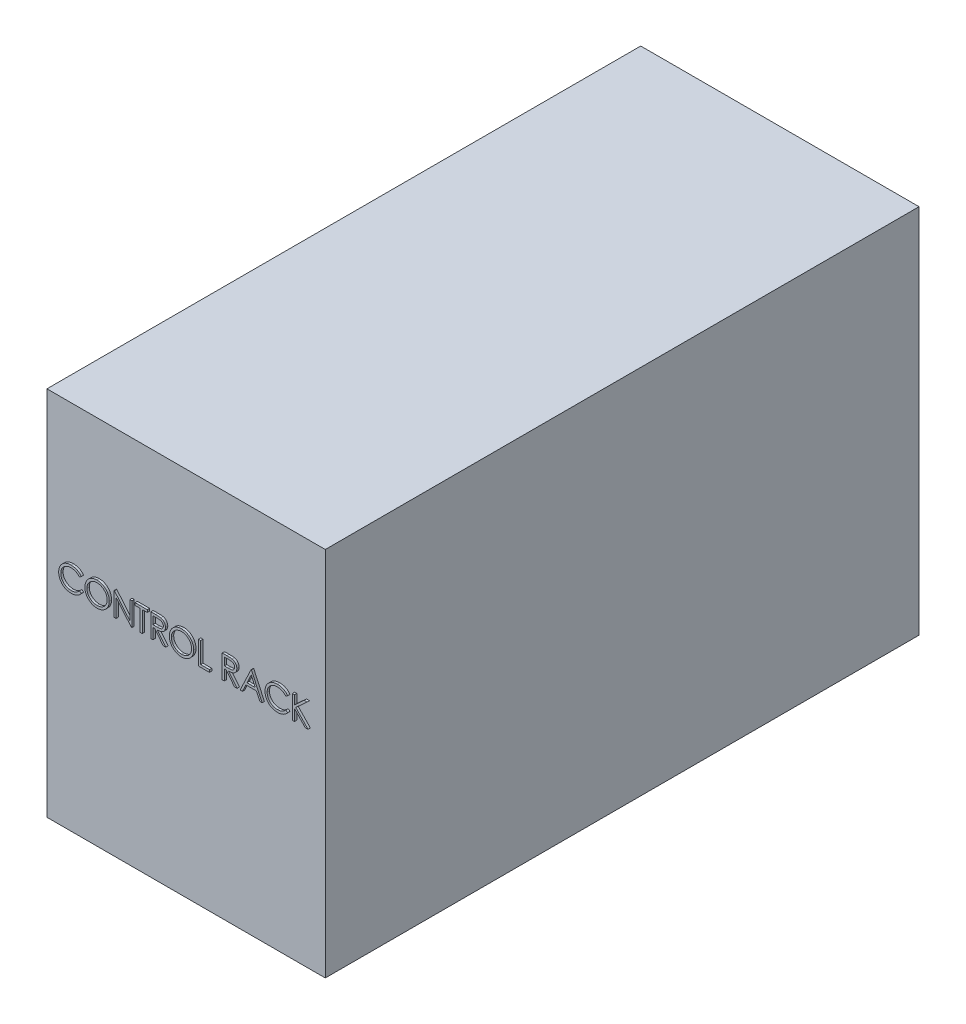
from build123d import *

# Parameters (mm, degrees)
SKETCH1_W           = 600
SKETCH1_H           = 800
BOSS_EXTRUDE1_DEPTH = 1280
BOSS_EXTRUDE2_DEPTH = 5


with BuildPart() as part:
    # Sketch1 → Boss-Extrude1 (new body)
    with BuildSketch(Plane.XY):
        with Locations((-300, 400)):
            Rectangle(SKETCH1_W, SKETCH1_H)
    extrude(amount=BOSS_EXTRUDE1_DEPTH)

    # Sketch2 → Boss-Extrude2 (add)
    with BuildSketch(Plane.XY.offset(1280)):
        with BuildLine():
            Line((-520.987509976, 491.534086131), (-524.913792027, 488.529278439))
            add(Edge.make_bspline(
                [(-524.913792027, 488.529278439), (-525.193876147, 488.863078008), (-525.750268244, 489.526176804), (-526.645399709, 490.457313153), (-527.578280321, 491.329674031), (-528.548553482, 492.147415168), (-529.57368376, 492.881940393), (-530.628838027, 493.571527578), (-531.731667244, 494.18963812), (-533.256692025, 494.93910935), (-535.251661286, 495.721197279), (-537.76301613, 496.376957726), (-540.384603251, 496.794403093), (-542.173140388, 496.839615114), (-543.08286254, 496.862611772)],
                knots=[0, 0, 0, 0, 0.001306928, 0.002596236, 0.003871776, 0.005137526, 0.006399704, 0.007652669, 0.008917388, 0.010189541, 0.012748886, 0.015328999, 0.017963804, 0.020691273, 0.020691273, 0.020691273, 0.020691273], degree=3))
            add(Edge.make_bspline(
                [(-543.08286254, 496.862611772), (-543.584052531, 496.856840879), (-544.581780996, 496.845352652), (-546.062473474, 496.693793721), (-547.515517062, 496.480776434), (-548.939966579, 496.164700388), (-550.334008844, 495.765091544), (-551.706757445, 495.287585631), (-553.038337442, 494.696802205), (-554.347169417, 494.043827062), (-555.601158145, 493.306292138), (-556.787658828, 492.501815682), (-557.902344084, 491.639400019), (-558.946095686, 490.715812785), (-559.919980662, 489.735213349), (-560.816942245, 488.687151327), (-561.633876677, 487.574977419), (-562.386977035, 486.413357311), (-563.061444655, 485.205674574), (-563.626157217, 483.947459282), (-564.126230392, 482.66025781), (-564.521933858, 481.329526941), (-564.835141241, 479.964630286), (-565.051250717, 478.561904744), (-565.20108602, 477.124280749), (-565.212517118, 476.149861998), (-565.218279207, 475.65868549)],
                knots=[0, 0, 0, 0, 0.001502938, 0.002991927, 0.004460872, 0.005906862, 0.007365217, 0.008809749, 0.010263039, 0.011732257, 0.013195831, 0.014623739, 0.016030161, 0.017420911, 0.018801997, 0.020173022, 0.02155527, 0.022938824, 0.024324153, 0.025700181, 0.027072961, 0.028464036, 0.029861154, 0.031270712, 0.03271982, 0.034192721, 0.034192721, 0.034192721, 0.034192721], degree=3))
            add(Edge.make_bspline(
                [(-565.218279207, 475.65868549), (-565.200253221, 474.919666634), (-565.164861588, 473.468701136), (-564.849885387, 471.3434067), (-564.371241226, 469.307397074), (-563.653875841, 467.373399327), (-562.769317976, 465.51756564), (-561.651594954, 463.771296306), (-560.357072992, 462.108202527), (-558.867438428, 460.567588988), (-557.233069628, 459.160250055), (-555.479528034, 457.920956034), (-553.611181066, 456.887886284), (-551.648657777, 456.028229905), (-549.57685615, 455.36741951), (-547.39950183, 454.902217746), (-545.121330469, 454.598758024), (-543.564624756, 454.569705337), (-542.772365745, 454.554919464)],
                knots=[0, 0, 0, 0, 0.002215807, 0.004350442, 0.006432355, 0.008479254, 0.010526472, 0.012588314, 0.014686091, 0.01683956, 0.019005825, 0.021148272, 0.023269069, 0.025399683, 0.027566295, 0.029780381, 0.032072497, 0.034448006, 0.034448006, 0.034448006, 0.034448006], degree=3))
            add(Edge.make_bspline(
                [(-542.772365745, 454.554919464), (-541.899470188, 454.579044889), (-540.181402918, 454.626529497), (-537.661859684, 455.028804484), (-535.249920175, 455.681060454), (-532.945454653, 456.593887915), (-530.754959708, 457.780534885), (-528.675007417, 459.219075991), (-526.703842125, 460.923195031), (-525.518538093, 462.224382577), (-524.913792027, 462.888252798)],
                knots=[0, 0, 0, 0, 0.002617423, 0.005151715, 0.007632497, 0.01010063, 0.0125699, 0.015089841, 0.017674403, 0.020366646, 0.020366646, 0.020366646, 0.020366646], degree=3))
            Line((-524.913792027, 462.888252798), (-520.987509976, 459.913493182))
            add(Edge.make_bspline(
                [(-520.987509976, 459.913493182), (-521.303482974, 459.505801012), (-521.933915478, 458.692369494), (-522.954744292, 457.545630783), (-524.030134255, 456.467001705), (-525.168072969, 455.465178544), (-526.355469992, 454.52011475), (-527.613645883, 453.658660018), (-528.926060633, 452.868790242), (-530.288267474, 452.145548463), (-531.698819086, 451.503873506), (-533.156025299, 450.954533966), (-534.653604949, 450.481321258), (-536.191626498, 450.092007877), (-537.773280167, 449.78813525), (-539.392858368, 449.584997038), (-541.053856586, 449.445826832), (-542.174448316, 449.43314232), (-542.742317668, 449.426714336)],
                knots=[0, 0, 0, 0, 0.001547046, 0.003086683, 0.004602316, 0.006113674, 0.007632581, 0.00915228, 0.010684502, 0.012225799, 0.013776731, 0.015330023, 0.016894897, 0.018486058, 0.020087025, 0.021723198, 0.023380963, 0.025084159, 0.025084159, 0.025084159, 0.025084159], degree=3))
            add(Edge.make_bspline(
                [(-542.742317668, 449.426714336), (-543.28008434, 449.430457087), (-544.343451342, 449.437857913), (-545.913433508, 449.557746019), (-547.441856091, 449.721313689), (-548.924350746, 449.967601276), (-550.369007532, 450.258234705), (-551.762730168, 450.647824085), (-553.119233173, 451.084240751), (-554.433066611, 451.597169133), (-555.705348037, 452.175971741), (-556.931973914, 452.830136868), (-558.112380091, 453.554163506), (-559.258171817, 454.332092226), (-560.352423013, 455.188910825), (-561.404616232, 456.112719889), (-562.420651607, 457.100405757), (-563.049261392, 457.812617947), (-563.365314463, 458.170704721)],
                knots=[0, 0, 0, 0, 0.00161286, 0.003189231, 0.004721159, 0.006222895, 0.00769617, 0.009139486, 0.010561656, 0.011969683, 0.013368094, 0.014752662, 0.016137194, 0.017520712, 0.018905171, 0.020303439, 0.021719989, 0.023152386, 0.023152386, 0.023152386, 0.023152386], degree=3))
            add(Edge.make_bspline(
                [(-563.365314463, 458.170704721), (-563.871537942, 458.792721705), (-564.877873325, 460.02924614), (-566.16538309, 462.033331586), (-567.267491021, 464.12573457), (-568.158575604, 466.317447838), (-568.855186078, 468.60355337), (-569.337774579, 470.985203576), (-569.651368928, 473.460174179), (-569.687230197, 475.143556874), (-569.705458694, 475.999230362)],
                knots=[0, 0, 0, 0, 0.002404368, 0.004779708, 0.007131768, 0.009490218, 0.011866572, 0.014290574, 0.016772771, 0.019338829, 0.019338829, 0.019338829, 0.019338829], degree=3))
            add(Edge.make_bspline(
                [(-569.705458694, 475.999230362), (-569.683241643, 476.898593984), (-569.639530983, 478.668035763), (-569.268162476, 481.264806524), (-568.670751102, 483.752683651), (-567.822224122, 486.127022859), (-566.746433389, 488.400312577), (-565.417481762, 490.555186932), (-563.850808302, 492.605426927), (-562.058700192, 494.519923374), (-560.093452545, 496.270485554), (-557.988898061, 497.810574179), (-555.749155962, 499.092252979), (-553.398900938, 500.163626728), (-550.920534058, 500.987119059), (-548.319343071, 501.563593154), (-545.600215717, 501.922409101), (-543.745038207, 501.967769214), (-542.802413822, 501.9908169)],
                knots=[0, 0, 0, 0, 0.00269699, 0.00530616, 0.007852064, 0.010361113, 0.012856571, 0.01538349, 0.017941678, 0.020585017, 0.023238413, 0.025826834, 0.028393517, 0.030966525, 0.033563748, 0.036212376, 0.038949263, 0.041776339, 0.041776339, 0.041776339, 0.041776339], degree=3))
            add(Edge.make_bspline(
                [(-542.802413822, 501.9908169), (-542.227921366, 501.983929212), (-541.090771404, 501.970295726), (-539.408590656, 501.837350839), (-537.770843128, 501.615727893), (-536.176400527, 501.314069752), (-534.61750601, 500.939679446), (-533.106073998, 500.451960898), (-531.633235614, 499.894296165), (-530.208279783, 499.252032366), (-528.838043352, 498.531078918), (-527.522953088, 497.739427153), (-526.273455106, 496.878058503), (-525.080757271, 495.954298854), (-523.964811399, 494.94860515), (-522.893933134, 493.888639493), (-521.90448916, 492.743870576), (-521.293729232, 491.938085806), (-520.987509976, 491.534086131)],
                knots=[0, 0, 0, 0, 0.001723222, 0.003410945, 0.00505836, 0.006679008, 0.008277466, 0.009864461, 0.011440036, 0.013000095, 0.014550251, 0.016082473, 0.017602172, 0.019100832, 0.020604704, 0.022106173, 0.02361846, 0.025139083, 0.025139083, 0.025139083, 0.025139083], degree=3))
        make_face()
        with BuildLine():
            add(Edge.make_bspline(
                [(-487.333663822, 501.9908169), (-486.407833738, 501.967367195), (-484.589427067, 501.921310039), (-481.916928528, 501.568751417), (-479.365570024, 500.958817274), (-476.914568041, 500.146488953), (-474.593239804, 499.062854876), (-472.384112769, 497.753067043), (-470.292443143, 496.203403346), (-468.346423406, 494.425842963), (-466.565609831, 492.491793621), (-464.996668599, 490.427823477), (-463.681778688, 488.246412016), (-462.601981729, 485.954114435), (-461.754858733, 483.556114893), (-461.170300966, 481.039629139), (-460.796898821, 478.420962138), (-460.753244858, 476.634864071), (-460.731099719, 475.728797669)],
                knots=[0, 0, 0, 0, 0.002777041, 0.005454338, 0.008068425, 0.01063716, 0.01318702, 0.015737884, 0.018330081, 0.020981964, 0.023633205, 0.026207343, 0.028746163, 0.031259727, 0.033797105, 0.036360151, 0.038999083, 0.041716086, 0.041716086, 0.041716086, 0.041716086], degree=3))
            add(Edge.make_bspline(
                [(-460.731099719, 475.728797669), (-460.753241613, 474.829405579), (-460.796885849, 473.056599572), (-461.170725528, 470.45455037), (-461.757025528, 467.953254706), (-462.594115045, 465.556888238), (-463.668764737, 463.262923041), (-464.992410039, 461.077395128), (-466.551570193, 458.999588009), (-468.325953779, 457.05226422), (-470.260254379, 455.266586067), (-472.334972476, 453.710602129), (-474.503448475, 452.371686063), (-476.793587163, 451.303347863), (-479.175016261, 450.449463286), (-481.669049448, 449.867282857), (-484.26400022, 449.491753667), (-486.033585988, 449.448632011), (-486.933022796, 449.426714336)],
                knots=[0, 0, 0, 0, 0.00269699, 0.005316081, 0.007869381, 0.010393996, 0.012916623, 0.015455444, 0.018045589, 0.020697472, 0.023348712, 0.025930847, 0.028466307, 0.03097987, 0.033498358, 0.036041916, 0.038651085, 0.041348076, 0.041348076, 0.041348076, 0.041348076], degree=3))
            add(Edge.make_bspline(
                [(-486.933022796, 449.426714336), (-487.839084496, 449.448848434), (-489.625173295, 449.492480633), (-492.247130944, 449.866500702), (-494.765384427, 450.45137647), (-497.172732302, 451.287225559), (-499.47051701, 452.367471712), (-501.663232477, 453.684677127), (-503.742077438, 455.247636287), (-505.689816673, 457.021444495), (-507.471948076, 458.952466667), (-509.025653443, 461.021527454), (-510.343155062, 463.188033977), (-511.419774097, 465.457998608), (-512.272123517, 467.820447789), (-512.853620919, 470.291140325), (-513.229848805, 472.855990408), (-513.273203755, 474.602317527), (-513.295202284, 475.488413054)],
                knots=[0, 0, 0, 0, 0.002717003, 0.005355936, 0.007928729, 0.010462803, 0.01298543, 0.015532831, 0.018122976, 0.020774859, 0.023426099, 0.025994209, 0.02852446, 0.031019918, 0.033519534, 0.036043612, 0.038623026, 0.041279992, 0.041279992, 0.041279992, 0.041279992], degree=3))
            add(Edge.make_bspline(
                [(-513.295202284, 475.488413054), (-513.287564634, 476.08316547), (-513.272385686, 477.265167235), (-513.089647222, 479.02040438), (-512.824480062, 480.747413776), (-512.44445274, 482.441284462), (-511.947428926, 484.097869957), (-511.360971391, 485.728595141), (-510.644687886, 487.316934051), (-509.834964343, 488.870411076), (-508.931224228, 490.364809731), (-507.932999236, 491.777375204), (-506.875351115, 493.119960872), (-505.715874063, 494.357775213), (-504.492781989, 495.526827447), (-503.18623373, 496.609151976), (-501.804201668, 497.614508418), (-500.3407391, 498.520513291), (-498.831906601, 499.3399295), (-497.276524062, 500.043098799), (-495.695715897, 500.646613964), (-494.08207807, 501.13576861), (-492.439895611, 501.521940552), (-490.765584403, 501.784902748), (-489.060478314, 501.968107289), (-487.911745186, 501.983214461), (-487.333663822, 501.9908169)],
                knots=[0, 0, 0, 0, 0.001783556, 0.003544611, 0.005288464, 0.007023435, 0.008747414, 0.010474271, 0.012218383, 0.013970071, 0.015727334, 0.017452942, 0.019156402, 0.020850296, 0.022536442, 0.02422924, 0.025936201, 0.027659336, 0.029389182, 0.031083519, 0.032776316, 0.034461928, 0.036138318, 0.037832715, 0.039543932, 0.041277428, 0.041277428, 0.041277428, 0.041277428], degree=3))
        make_face()
        with BuildLine():
            add(Edge.make_bspline(
                [(-487.113311258, 496.862611772), (-487.587806023, 496.856827625), (-488.532259351, 496.845314629), (-489.936324154, 496.69366155), (-491.321923209, 496.477520279), (-492.689342668, 496.169212839), (-494.032861088, 495.749154942), (-495.365001676, 495.265713397), (-496.673616731, 494.676840674), (-497.954386129, 494.011516326), (-499.19603006, 493.275103172), (-500.367640081, 492.461220785), (-501.47224928, 491.588955725), (-502.50715309, 490.656272334), (-503.469312692, 489.65842088), (-504.37766557, 488.610528935), (-505.195802451, 487.482644777), (-505.945596405, 486.305353251), (-506.616565552, 485.080187805), (-507.213213477, 483.820046915), (-507.701270745, 482.51465139), (-508.099304692, 481.178163424), (-508.42930199, 479.812699715), (-508.638358049, 478.407901874), (-508.791677469, 476.970828845), (-508.802532404, 475.999659502), (-508.808022796, 475.508445105)],
                knots=[0, 0, 0, 0, 0.00142284, 0.002832077, 0.004231743, 0.005628862, 0.007032428, 0.008452092, 0.00987789, 0.011333835, 0.012780172, 0.014205477, 0.015610187, 0.017000143, 0.018381374, 0.019766522, 0.021156839, 0.022557257, 0.023951357, 0.025344881, 0.026736387, 0.028127462, 0.02952684, 0.030946292, 0.032385431, 0.033858332, 0.033858332, 0.033858332, 0.033858332], degree=3))
            add(Edge.make_bspline(
                [(-508.808022796, 475.508445105), (-508.789810483, 474.786127665), (-508.753981228, 473.365105804), (-508.440301654, 471.282703749), (-507.957130591, 469.281442515), (-507.244882499, 467.372272383), (-506.354159432, 465.538782628), (-505.253775286, 463.797238275), (-503.950074063, 462.147168641), (-502.46916654, 460.60009337), (-500.850270732, 459.188010453), (-499.131231733, 457.948533186), (-497.330465911, 456.899815332), (-495.443277301, 456.045457155), (-493.479741029, 455.368460901), (-491.427204586, 454.904480456), (-489.299340878, 454.599116808), (-487.848902947, 454.569791723), (-487.113311258, 454.554919464)],
                knots=[0, 0, 0, 0, 0.002165779, 0.004260757, 0.006303756, 0.008331847, 0.01036105, 0.012409076, 0.014498972, 0.016659673, 0.018824919, 0.020934713, 0.023008224, 0.025065634, 0.027140306, 0.029227344, 0.031370516, 0.033575884, 0.033575884, 0.033575884, 0.033575884], degree=3))
            add(Edge.make_bspline(
                [(-487.113311258, 454.554919464), (-486.618889806, 454.561712384), (-485.638303572, 454.575184783), (-484.17979611, 454.710880167), (-482.747564514, 454.928478301), (-481.343617659, 455.241773381), (-479.969548925, 455.63387633), (-478.619623166, 456.099701016), (-477.308219018, 456.680861068), (-476.018792764, 457.322974662), (-474.78456074, 458.054976913), (-473.60633885, 458.841236193), (-472.513824852, 459.712216489), (-471.47969526, 460.631042383), (-470.513585418, 461.616240209), (-469.6220285, 462.666529093), (-468.808026612, 463.788538482), (-468.058517375, 464.964044278), (-467.389899336, 466.192562174), (-466.807340778, 467.457271859), (-466.313110552, 468.755059135), (-465.914131911, 470.087795871), (-465.601482459, 471.452950853), (-465.386055031, 472.85235197), (-465.235363051, 474.28319972), (-465.224004805, 475.250969091), (-465.218279207, 475.738813695)],
                knots=[0, 0, 0, 0, 0.001482913, 0.002941062, 0.004390205, 0.005826413, 0.007253126, 0.008675437, 0.010106362, 0.011553184, 0.012994413, 0.014408412, 0.015799053, 0.017182317, 0.018556375, 0.019935026, 0.021311346, 0.022711764, 0.024114651, 0.025503957, 0.026886096, 0.028277171, 0.029674289, 0.031083847, 0.032522987, 0.033985875, 0.033985875, 0.033985875, 0.033985875], degree=3))
            add(Edge.make_bspline(
                [(-465.218279207, 475.738813695), (-465.224009392, 476.223320899), (-465.23537627, 477.184430187), (-465.385983051, 478.605299021), (-465.601710056, 479.994630613), (-465.912605885, 481.346970656), (-466.313322367, 482.662663871), (-466.807427087, 483.940474553), (-467.390074222, 485.185163054), (-468.058763142, 486.393653011), (-468.810417763, 487.553292125), (-469.631764096, 488.661898018), (-470.536983355, 489.698651466), (-471.500212282, 490.689147095), (-472.545510644, 491.612259804), (-473.668143416, 492.468295813), (-474.85448167, 493.277914017), (-476.110585033, 494.008279186), (-477.40692723, 494.682768225), (-478.737126629, 495.260639699), (-480.086113767, 495.751669975), (-481.450458229, 496.170483762), (-482.841643633, 496.476312764), (-484.25026976, 496.693856333), (-485.674387739, 496.845261846), (-486.632148021, 496.856810111), (-487.113311258, 496.862611772)],
                knots=[0, 0, 0, 0, 0.001452876, 0.002882048, 0.004281713, 0.005669068, 0.007040971, 0.008404402, 0.009775537, 0.011160866, 0.01254442, 0.013918625, 0.015296183, 0.016670242, 0.018060991, 0.019475345, 0.020903252, 0.022366826, 0.023831668, 0.025284958, 0.026714024, 0.028136758, 0.02956319, 0.030982641, 0.032411812, 0.033854676, 0.033854676, 0.033854676, 0.033854676], degree=3))
        make_face(mode=Mode.SUBTRACT)
        Polygon((-450.474689463, 450.708765618), (-450.474689463, 500.708765618), (-449.533183053, 500.708765618), (-416.500330489, 461.355800875), (-416.500330489, 500.708765618), (-412.013151002, 500.708765618), (-412.013151002, 450.708765618), (-413.034785617, 450.708765618), (-445.987509976, 489.971586131), (-445.987509976, 450.708765618), align=None)
        Polygon((-404.96186895, 495.58056049), (-404.96186895, 500.708765618), (-378.679817668, 500.708765618), (-378.679817668, 495.58056049), (-389.577253566, 495.58056049), (-389.577253566, 450.708765618), (-394.064433053, 450.708765618), (-394.064433053, 495.58056049), align=None)
        with BuildLine():
            Line((-370.987509976, 500.708765618), (-360.98150036, 500.708765618))
            add(Edge.make_bspline(
                [(-360.98150036, 500.708765618), (-360.313769953, 500.706542961), (-359.031653604, 500.702275214), (-357.194892599, 500.678478601), (-355.525934071, 500.610273519), (-354.025650652, 500.551579469), (-352.694069867, 500.444551736), (-351.52710857, 500.342256777), (-350.530141463, 500.208347338), (-349.926629302, 500.083984152), (-349.65337536, 500.027675875)],
                knots=[0, 0, 0, 0, 0.00200323, 0.003846424, 0.00551017, 0.007014209, 0.0083501, 0.009517171, 0.010528542, 0.011365345, 0.011365345, 0.011365345, 0.011365345], degree=3))
            add(Edge.make_bspline(
                [(-349.65337536, 500.027675875), (-349.287566444, 499.937293512), (-348.563752309, 499.758456889), (-347.521608508, 499.380462591), (-346.528546738, 498.943039382), (-345.588692104, 498.429271949), (-344.70675223, 497.835346525), (-343.873633505, 497.171516205), (-343.085555456, 496.441413265), (-342.374389311, 495.626629815), (-341.70383143, 494.771822534), (-341.138279622, 493.84748315), (-340.650758484, 492.8808899), (-340.262608241, 491.862212504), (-339.950065763, 490.801330048), (-339.729690914, 489.688632952), (-339.597531091, 488.529190451), (-339.584076012, 487.738363183), (-339.577253566, 487.337371387)],
                knots=[0, 0, 0, 0, 0.001129726, 0.002235352, 0.003320462, 0.004382822, 0.005444001, 0.006506125, 0.007576154, 0.008661634, 0.009747438, 0.010831438, 0.011906471, 0.012990888, 0.014097058, 0.01522064, 0.016389772, 0.017592363, 0.017592363, 0.017592363, 0.017592363], degree=3))
            add(Edge.make_bspline(
                [(-339.577253566, 487.337371387), (-339.598239253, 486.671155607), (-339.639187764, 485.371196066), (-340.02097496, 483.484612046), (-340.646353813, 481.724764694), (-341.508115084, 480.093869866), (-342.605536166, 478.62371779), (-343.924461753, 477.332425571), (-345.465627632, 476.251855391), (-346.900332145, 475.50252961), (-348.167677855, 475.022630915), (-349.211010895, 474.684968646), (-350.349110573, 474.424083428), (-351.571072496, 474.190367259), (-352.88198186, 474.013914482), (-354.278696709, 473.884677418), (-355.762213161, 473.803905294), (-356.781342723, 473.791876653), (-357.30561895, 473.785688695)],
                knots=[0, 0, 0, 0, 0.00199681, 0.003896293, 0.005746413, 0.007583473, 0.009408398, 0.011228698, 0.013096305, 0.015036029, 0.016066512, 0.017159361, 0.018323032, 0.019566512, 0.02089094, 0.022289243, 0.023773779, 0.025346582, 0.025346582, 0.025346582, 0.025346582], degree=3))
            Line((-357.30561895, 473.785688695), (-338.936227925, 450.708765618))
            Line((-338.936227925, 450.708765618), (-344.48510613, 450.708765618))
            Line((-344.48510613, 450.708765618), (-362.854497155, 473.785688695))
            Line((-362.854497155, 473.785688695), (-366.500330489, 473.785688695))
            Line((-366.500330489, 473.785688695), (-366.500330489, 450.708765618))
            Line((-366.500330489, 450.708765618), (-370.987509976, 450.708765618))
            Line((-370.987509976, 450.708765618), (-370.987509976, 500.708765618))
        make_face()
        with BuildLine():
            Line((-366.500330489, 495.58056049), (-366.500330489, 478.913893823))
            Line((-366.500330489, 478.913893823), (-357.345683053, 478.843781644))
            add(Edge.make_bspline(
                [(-357.345683053, 478.843781644), (-356.918253925, 478.843592549), (-356.089774538, 478.843226029), (-354.891193612, 478.900279975), (-353.775192016, 478.965184521), (-352.746038414, 479.064460886), (-351.803273052, 479.192404768), (-350.947367149, 479.3524474), (-350.176923551, 479.538905438), (-349.278373002, 479.827500092), (-348.274993982, 480.284728924), (-347.184544556, 480.949950334), (-346.255939731, 481.786652037), (-345.47139884, 482.743415694), (-344.840978391, 483.795362106), (-344.396520472, 484.929881667), (-344.114485582, 486.118333067), (-344.081220647, 486.935163179), (-344.064433053, 487.347387413)],
                knots=[0, 0, 0, 0, 0.00128209, 0.002485056, 0.003599044, 0.004635545, 0.005586013, 0.006452327, 0.007246693, 0.007962541, 0.009280552, 0.010545033, 0.011779404, 0.013010561, 0.014245623, 0.015441563, 0.016653999, 0.017889263, 0.017889263, 0.017889263, 0.017889263], degree=3))
            add(Edge.make_bspline(
                [(-344.064433053, 487.347387413), (-344.081606211, 487.749481323), (-344.115637145, 488.546284733), (-344.393476695, 489.712797737), (-344.863325, 490.813754168), (-345.496499828, 491.844675382), (-346.267916327, 492.780471608), (-347.172456509, 493.581145223), (-348.185387868, 494.241851862), (-349.132119273, 494.664057298), (-349.978322309, 494.922912344), (-350.713031738, 495.105071827), (-351.543195705, 495.251421383), (-352.472845114, 495.368679396), (-353.498011268, 495.469464313), (-354.623877712, 495.537346866), (-355.842974573, 495.577544924), (-356.687930733, 495.579531908), (-357.125330489, 495.58056049)],
                knots=[0, 0, 0, 0, 0.001205299, 0.002388462, 0.003573447, 0.004782776, 0.006006208, 0.007198157, 0.008392755, 0.00962126, 0.010292857, 0.011045926, 0.011890723, 0.012820003, 0.013856505, 0.014980488, 0.0162031, 0.017515238, 0.017515238, 0.017515238, 0.017515238], degree=3))
            Line((-357.125330489, 495.58056049), (-366.500330489, 495.58056049))
        make_face(mode=Mode.SUBTRACT)
        with BuildLine():
            add(Edge.make_bspline(
                [(-305.282381771, 501.9908169), (-304.356551686, 501.967367195), (-302.538145016, 501.921310039), (-299.865646477, 501.568751417), (-297.314287973, 500.958817274), (-294.86328599, 500.146488953), (-292.541957753, 499.062854876), (-290.332830717, 497.753067043), (-288.241161091, 496.203403346), (-286.295141355, 494.425842963), (-284.51432778, 492.491793621), (-282.945386547, 490.427823477), (-281.630496637, 488.246412016), (-280.550699677, 485.954114435), (-279.703576682, 483.556114893), (-279.119018915, 481.039629139), (-278.74561677, 478.420962138), (-278.701962807, 476.634864071), (-278.679817668, 475.728797669)],
                knots=[0, 0, 0, 0, 0.002777041, 0.005454338, 0.008068425, 0.01063716, 0.01318702, 0.015737884, 0.018330081, 0.020981964, 0.023633205, 0.026207343, 0.028746163, 0.031259727, 0.033797105, 0.036360151, 0.038999083, 0.041716086, 0.041716086, 0.041716086, 0.041716086], degree=3))
            add(Edge.make_bspline(
                [(-278.679817668, 475.728797669), (-278.701959561, 474.829405579), (-278.745603798, 473.056599572), (-279.119443477, 470.45455037), (-279.705743477, 467.953254706), (-280.542832994, 465.556888238), (-281.617482686, 463.262923041), (-282.941127988, 461.077395128), (-284.500288141, 458.999588009), (-286.274671728, 457.05226422), (-288.208972328, 455.266586067), (-290.283690425, 453.710602129), (-292.452166424, 452.371686063), (-294.742305112, 451.303347863), (-297.123734209, 450.449463286), (-299.617767396, 449.867282857), (-302.212718168, 449.491753667), (-303.982303937, 449.448632011), (-304.881740745, 449.426714336)],
                knots=[0, 0, 0, 0, 0.00269699, 0.005316081, 0.007869381, 0.010393996, 0.012916623, 0.015455444, 0.018045589, 0.020697472, 0.023348712, 0.025930847, 0.028466307, 0.03097987, 0.033498358, 0.036041916, 0.038651085, 0.041348076, 0.041348076, 0.041348076, 0.041348076], degree=3))
            add(Edge.make_bspline(
                [(-304.881740745, 449.426714336), (-305.787802445, 449.448848434), (-307.573891244, 449.492480633), (-310.195848892, 449.866500702), (-312.714102376, 450.45137647), (-315.12145025, 451.287225559), (-317.419234959, 452.367471712), (-319.611950426, 453.684677127), (-321.690795386, 455.247636287), (-323.638534622, 457.021444495), (-325.420666025, 458.952466667), (-326.974371392, 461.021527454), (-328.29187301, 463.188033977), (-329.368492046, 465.457998608), (-330.220841465, 467.820447789), (-330.802338867, 470.291140325), (-331.178566754, 472.855990408), (-331.221921704, 474.602317527), (-331.243920232, 475.488413054)],
                knots=[0, 0, 0, 0, 0.002717003, 0.005355936, 0.007928729, 0.010462803, 0.01298543, 0.015532831, 0.018122976, 0.020774859, 0.023426099, 0.025994209, 0.02852446, 0.031019918, 0.033519534, 0.036043612, 0.038623026, 0.041279992, 0.041279992, 0.041279992, 0.041279992], degree=3))
            add(Edge.make_bspline(
                [(-331.243920232, 475.488413054), (-331.236282582, 476.08316547), (-331.221103634, 477.265167235), (-331.038365171, 479.02040438), (-330.773198011, 480.747413776), (-330.393170688, 482.441284462), (-329.896146874, 484.097869957), (-329.30968934, 485.728595141), (-328.593405835, 487.316934051), (-327.783682292, 488.870411076), (-326.879942177, 490.364809731), (-325.881717185, 491.777375204), (-324.824069064, 493.119960872), (-323.664592012, 494.357775213), (-322.441499938, 495.526827447), (-321.134951679, 496.609151976), (-319.752919616, 497.614508418), (-318.289457048, 498.520513291), (-316.78062455, 499.3399295), (-315.22524201, 500.043098799), (-313.644433846, 500.646613964), (-312.030796018, 501.13576861), (-310.38861356, 501.521940552), (-308.714302352, 501.784902748), (-307.009196262, 501.968107289), (-305.860463134, 501.983214461), (-305.282381771, 501.9908169)],
                knots=[0, 0, 0, 0, 0.001783556, 0.003544611, 0.005288464, 0.007023435, 0.008747414, 0.010474271, 0.012218383, 0.013970071, 0.015727334, 0.017452942, 0.019156402, 0.020850296, 0.022536442, 0.02422924, 0.025936201, 0.027659336, 0.029389182, 0.031083519, 0.032776316, 0.034461928, 0.036138318, 0.037832715, 0.039543932, 0.041277428, 0.041277428, 0.041277428, 0.041277428], degree=3))
        make_face()
        with BuildLine():
            add(Edge.make_bspline(
                [(-305.062029207, 496.862611772), (-305.536523972, 496.856827625), (-306.480977299, 496.845314629), (-307.885042103, 496.69366155), (-309.270641157, 496.477520279), (-310.638060617, 496.169212839), (-311.981579037, 495.749154942), (-313.313719625, 495.265713397), (-314.62233468, 494.676840674), (-315.903104078, 494.011516326), (-317.144748009, 493.275103172), (-318.31635803, 492.461220785), (-319.420967229, 491.588955725), (-320.455871038, 490.656272334), (-321.418030641, 489.65842088), (-322.326383519, 488.610528935), (-323.144520399, 487.482644777), (-323.894314354, 486.305353251), (-324.565283501, 485.080187805), (-325.161931426, 483.820046915), (-325.649988694, 482.51465139), (-326.048022641, 481.178163424), (-326.378019939, 479.812699715), (-326.587075997, 478.407901874), (-326.740395418, 476.970828845), (-326.751250353, 475.999659502), (-326.756740745, 475.508445105)],
                knots=[0, 0, 0, 0, 0.00142284, 0.002832077, 0.004231743, 0.005628862, 0.007032428, 0.008452092, 0.00987789, 0.011333835, 0.012780172, 0.014205477, 0.015610187, 0.017000143, 0.018381374, 0.019766522, 0.021156839, 0.022557257, 0.023951357, 0.025344881, 0.026736387, 0.028127462, 0.02952684, 0.030946292, 0.032385431, 0.033858332, 0.033858332, 0.033858332, 0.033858332], degree=3))
            add(Edge.make_bspline(
                [(-326.756740745, 475.508445105), (-326.738528431, 474.786127665), (-326.702699176, 473.365105804), (-326.389019603, 471.282703749), (-325.90584854, 469.281442515), (-325.193600448, 467.372272383), (-324.302877381, 465.538782628), (-323.202493234, 463.797238275), (-321.898792012, 462.147168641), (-320.417884489, 460.60009337), (-318.79898868, 459.188010453), (-317.079949681, 457.948533186), (-315.27918386, 456.899815332), (-313.39199525, 456.045457155), (-311.428458978, 455.368460901), (-309.375922535, 454.904480456), (-307.248058826, 454.599116808), (-305.797620896, 454.569791723), (-305.062029207, 454.554919464)],
                knots=[0, 0, 0, 0, 0.002165779, 0.004260757, 0.006303756, 0.008331847, 0.01036105, 0.012409076, 0.014498972, 0.016659673, 0.018824919, 0.020934713, 0.023008224, 0.025065634, 0.027140306, 0.029227344, 0.031370516, 0.033575884, 0.033575884, 0.033575884, 0.033575884], degree=3))
            add(Edge.make_bspline(
                [(-305.062029207, 454.554919464), (-304.567607755, 454.561712384), (-303.587021521, 454.575184783), (-302.128514059, 454.710880167), (-300.696282463, 454.928478301), (-299.292335607, 455.241773381), (-297.918266873, 455.63387633), (-296.568341114, 456.099701016), (-295.256936967, 456.680861068), (-293.967510713, 457.322974662), (-292.733278689, 458.054976913), (-291.555056799, 458.841236193), (-290.462542801, 459.712216489), (-289.428413209, 460.631042383), (-288.462303366, 461.616240209), (-287.570746449, 462.666529093), (-286.756744561, 463.788538482), (-286.007235324, 464.964044278), (-285.338617284, 466.192562174), (-284.756058726, 467.457271859), (-284.2618285, 468.755059135), (-283.86284986, 470.087795871), (-283.550200407, 471.452950853), (-283.33477298, 472.85235197), (-283.184080999, 474.28319972), (-283.172722754, 475.250969091), (-283.166997155, 475.738813695)],
                knots=[0, 0, 0, 0, 0.001482913, 0.002941062, 0.004390205, 0.005826413, 0.007253126, 0.008675437, 0.010106362, 0.011553184, 0.012994413, 0.014408412, 0.015799053, 0.017182317, 0.018556375, 0.019935026, 0.021311346, 0.022711764, 0.024114651, 0.025503957, 0.026886096, 0.028277171, 0.029674289, 0.031083847, 0.032522987, 0.033985875, 0.033985875, 0.033985875, 0.033985875], degree=3))
            add(Edge.make_bspline(
                [(-283.166997155, 475.738813695), (-283.172727341, 476.223320899), (-283.184094219, 477.184430187), (-283.334700999, 478.605299021), (-283.550428005, 479.994630613), (-283.861323834, 481.346970656), (-284.262040316, 482.662663871), (-284.756145036, 483.940474553), (-285.338792171, 485.185163054), (-286.007481091, 486.393653011), (-286.759135712, 487.553292125), (-287.580482045, 488.661898018), (-288.485701304, 489.698651466), (-289.448930231, 490.689147095), (-290.494228593, 491.612259804), (-291.616861365, 492.468295813), (-292.803199619, 493.277914017), (-294.059302982, 494.008279186), (-295.355645178, 494.682768225), (-296.685844578, 495.260639699), (-298.034831715, 495.751669975), (-299.399176177, 496.170483762), (-300.790361582, 496.476312764), (-302.198987708, 496.693856333), (-303.623105688, 496.845261846), (-304.58086597, 496.856810111), (-305.062029207, 496.862611772)],
                knots=[0, 0, 0, 0, 0.001452876, 0.002882048, 0.004281713, 0.005669068, 0.007040971, 0.008404402, 0.009775537, 0.011160866, 0.01254442, 0.013918625, 0.015296183, 0.016670242, 0.018060991, 0.019475345, 0.020903252, 0.022366826, 0.023831668, 0.025284958, 0.026714024, 0.028136758, 0.02956319, 0.030982641, 0.032411812, 0.033854676, 0.033854676, 0.033854676, 0.033854676], degree=3))
        make_face(mode=Mode.SUBTRACT)
        Polygon((-268.423407412, 500.708765618), (-263.936227925, 500.708765618), (-263.936227925, 455.836970746), (-244.705458694, 455.836970746), (-244.705458694, 450.708765618), (-268.423407412, 450.708765618), align=None)
        with BuildLine():
            Line((-217.14135613, 500.708765618), (-207.135346514, 500.708765618))
            add(Edge.make_bspline(
                [(-207.135346514, 500.708765618), (-206.467616107, 500.706542961), (-205.185499758, 500.702275214), (-203.348738753, 500.678478601), (-201.679780225, 500.610273519), (-200.179496806, 500.551579469), (-198.84791602, 500.444551736), (-197.680954724, 500.342256777), (-196.683987617, 500.208347338), (-196.080475455, 500.083984152), (-195.807221514, 500.027675875)],
                knots=[0, 0, 0, 0, 0.00200323, 0.003846424, 0.00551017, 0.007014209, 0.0083501, 0.009517171, 0.010528542, 0.011365345, 0.011365345, 0.011365345, 0.011365345], degree=3))
            add(Edge.make_bspline(
                [(-195.807221514, 500.027675875), (-195.441412598, 499.937293512), (-194.717598463, 499.758456889), (-193.675454662, 499.380462591), (-192.682392891, 498.943039382), (-191.742538258, 498.429271949), (-190.860598384, 497.835346525), (-190.027479659, 497.171516205), (-189.23940161, 496.441413265), (-188.528235465, 495.626629815), (-187.857677583, 494.771822534), (-187.292125776, 493.84748315), (-186.804604637, 492.8808899), (-186.416454395, 491.862212504), (-186.103911916, 490.801330048), (-185.883537068, 489.688632952), (-185.751377245, 488.529190451), (-185.737922166, 487.738363183), (-185.731099719, 487.337371387)],
                knots=[0, 0, 0, 0, 0.001129726, 0.002235352, 0.003320462, 0.004382822, 0.005444001, 0.006506125, 0.007576154, 0.008661634, 0.009747438, 0.010831438, 0.011906471, 0.012990888, 0.014097058, 0.01522064, 0.016389772, 0.017592363, 0.017592363, 0.017592363, 0.017592363], degree=3))
            add(Edge.make_bspline(
                [(-185.731099719, 487.337371387), (-185.752085407, 486.671155607), (-185.793033918, 485.371196066), (-186.174821113, 483.484612046), (-186.800199967, 481.724764694), (-187.661961238, 480.093869866), (-188.75938232, 478.62371779), (-190.078307907, 477.332425571), (-191.619473786, 476.251855391), (-193.054178299, 475.50252961), (-194.321524009, 475.022630915), (-195.364857049, 474.684968646), (-196.502956727, 474.424083428), (-197.72491865, 474.190367259), (-199.035828014, 474.013914482), (-200.432542863, 473.884677418), (-201.916059315, 473.803905294), (-202.935188877, 473.791876653), (-203.459465104, 473.785688695)],
                knots=[0, 0, 0, 0, 0.00199681, 0.003896293, 0.005746413, 0.007583473, 0.009408398, 0.011228698, 0.013096305, 0.015036029, 0.016066512, 0.017159361, 0.018323032, 0.019566512, 0.02089094, 0.022289243, 0.023773779, 0.025346582, 0.025346582, 0.025346582, 0.025346582], degree=3))
            Line((-203.459465104, 473.785688695), (-185.090074078, 450.708765618))
            Line((-185.090074078, 450.708765618), (-190.638952284, 450.708765618))
            Line((-190.638952284, 450.708765618), (-209.008343309, 473.785688695))
            Line((-209.008343309, 473.785688695), (-212.654176643, 473.785688695))
            Line((-212.654176643, 473.785688695), (-212.654176643, 450.708765618))
            Line((-212.654176643, 450.708765618), (-217.14135613, 450.708765618))
            Line((-217.14135613, 450.708765618), (-217.14135613, 500.708765618))
        make_face()
        with BuildLine():
            Line((-212.654176643, 495.58056049), (-212.654176643, 478.913893823))
            Line((-212.654176643, 478.913893823), (-203.499529207, 478.843781644))
            add(Edge.make_bspline(
                [(-203.499529207, 478.843781644), (-203.072100079, 478.843592549), (-202.243620692, 478.843226029), (-201.045039766, 478.900279975), (-199.92903817, 478.965184521), (-198.899884568, 479.064460886), (-197.957119206, 479.192404768), (-197.101213303, 479.3524474), (-196.330769704, 479.538905438), (-195.432219156, 479.827500092), (-194.428840136, 480.284728924), (-193.338390709, 480.949950334), (-192.409785884, 481.786652037), (-191.625244994, 482.743415694), (-190.994824545, 483.795362106), (-190.550366626, 484.929881667), (-190.268331736, 486.118333067), (-190.235066801, 486.935163179), (-190.218279207, 487.347387413)],
                knots=[0, 0, 0, 0, 0.00128209, 0.002485056, 0.003599044, 0.004635545, 0.005586013, 0.006452327, 0.007246693, 0.007962541, 0.009280552, 0.010545033, 0.011779404, 0.013010561, 0.014245623, 0.015441563, 0.016653999, 0.017889263, 0.017889263, 0.017889263, 0.017889263], degree=3))
            add(Edge.make_bspline(
                [(-190.218279207, 487.347387413), (-190.235452365, 487.749481323), (-190.269483299, 488.546284733), (-190.547322849, 489.712797737), (-191.017171154, 490.813754168), (-191.650345982, 491.844675382), (-192.421762481, 492.780471608), (-193.326302662, 493.581145223), (-194.339234022, 494.241851862), (-195.285965427, 494.664057298), (-196.132168462, 494.922912344), (-196.866877892, 495.105071827), (-197.697041859, 495.251421383), (-198.626691268, 495.368679396), (-199.651857422, 495.469464313), (-200.777723866, 495.537346866), (-201.996820727, 495.577544924), (-202.841776887, 495.579531908), (-203.279176643, 495.58056049)],
                knots=[0, 0, 0, 0, 0.001205299, 0.002388462, 0.003573447, 0.004782776, 0.006006208, 0.007198157, 0.008392755, 0.00962126, 0.010292857, 0.011045926, 0.011890723, 0.012820003, 0.013856505, 0.014980488, 0.0162031, 0.017515238, 0.017515238, 0.017515238, 0.017515238], degree=3))
            Line((-203.279176643, 495.58056049), (-212.654176643, 495.58056049))
        make_face(mode=Mode.SUBTRACT)
        Polygon((-154.320843309, 500.708765618), (-131.243920232, 450.708765618), (-136.121724719, 450.708765618), (-143.513551643, 466.734406644), (-166.179817668, 466.734406644), (-173.78198113, 450.708765618), (-178.679817668, 450.708765618), (-154.96186895, 500.708765618), align=None)
        Polygon((-154.691436258, 490.963172669), (-163.745923437, 471.862611772), (-145.877333694, 471.862611772), align=None, mode=Mode.SUBTRACT)
        with BuildLine():
            Line((-76.115715104, 491.534086131), (-80.041997155, 488.529278439))
            add(Edge.make_bspline(
                [(-80.041997155, 488.529278439), (-80.322081275, 488.863078008), (-80.878473372, 489.526176804), (-81.773604837, 490.457313153), (-82.70648545, 491.329674031), (-83.67675861, 492.147415168), (-84.701888888, 492.881940393), (-85.757043155, 493.571527578), (-86.859872372, 494.18963812), (-88.384897153, 494.93910935), (-90.379866414, 495.721197279), (-92.891221258, 496.376957726), (-95.512808379, 496.794403093), (-97.301345517, 496.839615114), (-98.211067668, 496.862611772)],
                knots=[0, 0, 0, 0, 0.001306928, 0.002596236, 0.003871776, 0.005137526, 0.006399704, 0.007652669, 0.008917388, 0.010189541, 0.012748886, 0.015328999, 0.017963804, 0.020691273, 0.020691273, 0.020691273, 0.020691273], degree=3))
            add(Edge.make_bspline(
                [(-98.211067668, 496.862611772), (-98.712257659, 496.856840879), (-99.709986124, 496.845352652), (-101.190678603, 496.693793721), (-102.64372219, 496.480776434), (-104.068171708, 496.164700388), (-105.462213972, 495.765091544), (-106.834962573, 495.287585631), (-108.166542571, 494.696802205), (-109.475374545, 494.043827062), (-110.729363274, 493.306292138), (-111.915863956, 492.501815682), (-113.030549212, 491.639400019), (-114.074300814, 490.715812785), (-115.04818579, 489.735213349), (-115.945147373, 488.687151327), (-116.762081805, 487.574977419), (-117.515182164, 486.413357311), (-118.189649783, 485.205674574), (-118.754362346, 483.947459282), (-119.25443552, 482.66025781), (-119.650138986, 481.329526941), (-119.96334637, 479.964630286), (-120.179455845, 478.561904744), (-120.329291148, 477.124280749), (-120.340722246, 476.149861998), (-120.346484335, 475.65868549)],
                knots=[0, 0, 0, 0, 0.001502938, 0.002991927, 0.004460872, 0.005906862, 0.007365217, 0.008809749, 0.010263039, 0.011732257, 0.013195831, 0.014623739, 0.016030161, 0.017420911, 0.018801997, 0.020173022, 0.02155527, 0.022938824, 0.024324153, 0.025700181, 0.027072961, 0.028464036, 0.029861154, 0.031270712, 0.03271982, 0.034192721, 0.034192721, 0.034192721, 0.034192721], degree=3))
            add(Edge.make_bspline(
                [(-120.346484335, 475.65868549), (-120.328458349, 474.919666634), (-120.293066716, 473.468701136), (-119.978090515, 471.3434067), (-119.499446354, 469.307397074), (-118.782080969, 467.373399327), (-117.897523104, 465.51756564), (-116.779800082, 463.771296306), (-115.48527812, 462.108202527), (-113.995643556, 460.567588988), (-112.361274756, 459.160250055), (-110.607733162, 457.920956034), (-108.739386194, 456.887886284), (-106.776862905, 456.028229905), (-104.705061278, 455.36741951), (-102.527706958, 454.902217746), (-100.249535597, 454.598758024), (-98.692829884, 454.569705337), (-97.900570873, 454.554919464)],
                knots=[0, 0, 0, 0, 0.002215807, 0.004350442, 0.006432355, 0.008479254, 0.010526472, 0.012588314, 0.014686091, 0.01683956, 0.019005825, 0.021148272, 0.023269069, 0.025399683, 0.027566295, 0.029780381, 0.032072497, 0.034448006, 0.034448006, 0.034448006, 0.034448006], degree=3))
            add(Edge.make_bspline(
                [(-97.900570873, 454.554919464), (-97.027675316, 454.579044889), (-95.309608046, 454.626529497), (-92.790064813, 455.028804484), (-90.378125304, 455.681060454), (-88.073659782, 456.593887915), (-85.883164836, 457.780534885), (-83.803212546, 459.219075991), (-81.832047253, 460.923195031), (-80.646743221, 462.224382577), (-80.041997155, 462.888252798)],
                knots=[0, 0, 0, 0, 0.002617423, 0.005151715, 0.007632497, 0.01010063, 0.0125699, 0.015089841, 0.017674403, 0.020366646, 0.020366646, 0.020366646, 0.020366646], degree=3))
            Line((-80.041997155, 462.888252798), (-76.115715104, 459.913493182))
            add(Edge.make_bspline(
                [(-76.115715104, 459.913493182), (-76.431688102, 459.505801012), (-77.062120606, 458.692369494), (-78.08294942, 457.545630783), (-79.158339383, 456.467001705), (-80.296278097, 455.465178544), (-81.48367512, 454.52011475), (-82.741851011, 453.658660018), (-84.054265761, 452.868790242), (-85.416472602, 452.145548463), (-86.827024214, 451.503873506), (-88.284230427, 450.954533966), (-89.781810077, 450.481321258), (-91.319831626, 450.092007877), (-92.901485295, 449.78813525), (-94.521063496, 449.584997038), (-96.182061714, 449.445826832), (-97.302653444, 449.43314232), (-97.870522796, 449.426714336)],
                knots=[0, 0, 0, 0, 0.001547046, 0.003086683, 0.004602316, 0.006113674, 0.007632581, 0.00915228, 0.010684502, 0.012225799, 0.013776731, 0.015330023, 0.016894897, 0.018486058, 0.020087025, 0.021723198, 0.023380963, 0.025084159, 0.025084159, 0.025084159, 0.025084159], degree=3))
            add(Edge.make_bspline(
                [(-97.870522796, 449.426714336), (-98.408289469, 449.430457087), (-99.47165647, 449.437857913), (-101.041638636, 449.557746019), (-102.570061219, 449.721313689), (-104.052555874, 449.967601276), (-105.49721266, 450.258234705), (-106.890935296, 450.647824085), (-108.247438301, 451.084240751), (-109.56127174, 451.597169133), (-110.833553165, 452.175971741), (-112.060179042, 452.830136868), (-113.240585219, 453.554163506), (-114.386376946, 454.332092226), (-115.480628141, 455.188910825), (-116.53282136, 456.112719889), (-117.548856735, 457.100405757), (-118.177466521, 457.812617947), (-118.493519591, 458.170704721)],
                knots=[0, 0, 0, 0, 0.00161286, 0.003189231, 0.004721159, 0.006222895, 0.00769617, 0.009139486, 0.010561656, 0.011969683, 0.013368094, 0.014752662, 0.016137194, 0.017520712, 0.018905171, 0.020303439, 0.021719989, 0.023152386, 0.023152386, 0.023152386, 0.023152386], degree=3))
            add(Edge.make_bspline(
                [(-118.493519591, 458.170704721), (-118.99974307, 458.792721705), (-120.006078453, 460.02924614), (-121.293588218, 462.033331586), (-122.39569615, 464.12573457), (-123.286780732, 466.317447838), (-123.983391206, 468.60355337), (-124.465979707, 470.985203576), (-124.779574057, 473.460174179), (-124.815435325, 475.143556874), (-124.833663822, 475.999230362)],
                knots=[0, 0, 0, 0, 0.002404368, 0.004779708, 0.007131768, 0.009490218, 0.011866572, 0.014290574, 0.016772771, 0.019338829, 0.019338829, 0.019338829, 0.019338829], degree=3))
            add(Edge.make_bspline(
                [(-124.833663822, 475.999230362), (-124.811446771, 476.898593984), (-124.767736111, 478.668035763), (-124.396367604, 481.264806524), (-123.79895623, 483.752683651), (-122.95042925, 486.127022859), (-121.874638517, 488.400312577), (-120.545686891, 490.555186932), (-118.97901343, 492.605426927), (-117.186905321, 494.519923374), (-115.221657673, 496.270485554), (-113.117103189, 497.810574179), (-110.87736109, 499.092252979), (-108.527106066, 500.163626728), (-106.048739186, 500.987119059), (-103.447548199, 501.563593154), (-100.728420845, 501.922409101), (-98.873243335, 501.967769214), (-97.93061895, 501.9908169)],
                knots=[0, 0, 0, 0, 0.00269699, 0.00530616, 0.007852064, 0.010361113, 0.012856571, 0.01538349, 0.017941678, 0.020585017, 0.023238413, 0.025826834, 0.028393517, 0.030966525, 0.033563748, 0.036212376, 0.038949263, 0.041776339, 0.041776339, 0.041776339, 0.041776339], degree=3))
            add(Edge.make_bspline(
                [(-97.93061895, 501.9908169), (-97.356126494, 501.983929212), (-96.218976533, 501.970295726), (-94.536795784, 501.837350839), (-92.899048256, 501.615727893), (-91.304605656, 501.314069752), (-89.745711138, 500.939679446), (-88.234279126, 500.451960898), (-86.761440742, 499.894296165), (-85.336484911, 499.252032366), (-83.96624848, 498.531078918), (-82.651158216, 497.739427153), (-81.401660234, 496.878058503), (-80.2089624, 495.954298854), (-79.093016527, 494.94860515), (-78.022138262, 493.888639493), (-77.032694288, 492.743870576), (-76.42193436, 491.938085806), (-76.115715104, 491.534086131)],
                knots=[0, 0, 0, 0, 0.001723222, 0.003410945, 0.00505836, 0.006679008, 0.008277466, 0.009864461, 0.011440036, 0.013000095, 0.014550251, 0.016082473, 0.017602172, 0.019100832, 0.020604704, 0.022106173, 0.02361846, 0.025139083, 0.025139083, 0.025139083, 0.025139083], degree=3))
        make_face()
        Polygon((-65.859304848, 500.708765618), (-61.37212536, 500.708765618), (-61.37212536, 481.668300875), (-40.528776002, 500.708765618), (-34.128535617, 500.708765618), (-58.697846514, 478.272868182), (-32.205458694, 450.708765618), (-38.185026002, 450.708765618), (-61.37212536, 474.837371387), (-61.37212536, 450.708765618), (-65.859304848, 450.708765618), align=None)
    extrude(amount=BOSS_EXTRUDE2_DEPTH)


solid = part.part
